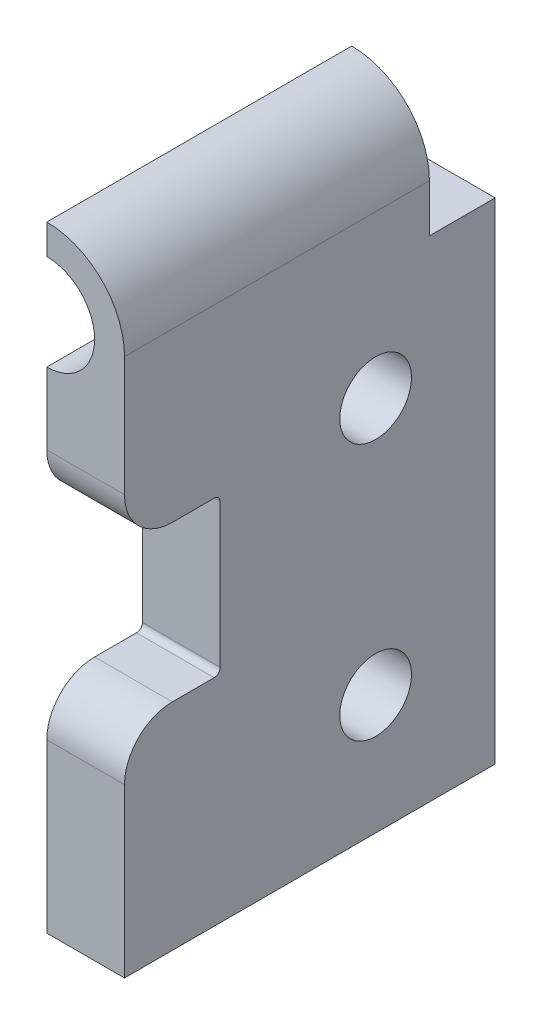
from build123d import *

# Parameters (mm, degrees)
BOSS_EXTRUDE1_DEPTH = 31
SKETCH2_W           = 5.5
SKETCH2_H           = 10.5
CUT_EXTRUDE1_DEPTH  = 7.5
SKETCH3_R           = 3
CUT_EXTRUDE2_DEPTH  = 7.5
CUT_EXTRUDE4_DEPTH  = 26.5
CUT_EXTRUDE5_REACH  = 8.5
SKETCH6_W           = 8
SKETCH6_H           = 13
FILLET1_R           = 0.5
FILLET2_R           = 4


with BuildPart() as part:
    # Sketch1 → Boss-Extrude1 (new body)
    with BuildSketch(Plane.XY):
        with BuildLine():
            Line((-3.75, 29), (-3.75, 22.5))
            Line((-3.75, 22.5), (-3.75, -22.5))
            Line((-3.75, -22.5), (2.75, -22.5))
            Line((2.75, -22.5), (2.75, 22.5))
            ThreePointArc((2.75, 22.5), (0.846194078, 27.096194078), (-3.75, 29))
        make_face()
    extrude(amount=BOSS_EXTRUDE1_DEPTH)

    # Sketch2 → Cut-Extrude1 (cut, through all)
    with BuildSketch(Plane.ZY.offset(3.75)):
        with Locations((2.75, 23.75)):
            Rectangle(SKETCH2_W, SKETCH2_H)
    extrude(amount=-CUT_EXTRUDE1_DEPTH, mode=Mode.SUBTRACT)

    # Sketch3 → Cut-Extrude2 (cut, through all)
    with BuildSketch(Plane.ZY.offset(3.75)):
        with Locations((10, 9)):
            Circle(SKETCH3_R)
        with Locations((10, -12.5)):
            Circle(SKETCH3_R)
    extrude(amount=-CUT_EXTRUDE2_DEPTH, mode=Mode.SUBTRACT)

    # Sketch4 → Cut-Extrude4 (cut, through all)
    with BuildSketch(Plane(origin=(0, 0, 5.5), x_dir=(-1, 0, 0), z_dir=(0, 0, -1))):
        with BuildLine():
            Line((3.75, 26.5), (3.75, 18.5))
            ThreePointArc((3.75, 18.5), (-0.25, 22.5), (3.75, 26.5))
        make_face()
    extrude(amount=-CUT_EXTRUDE4_DEPTH, mode=Mode.SUBTRACT)

    # Sketch6 → Cut-Extrude5 (cut, up to next)
    with BuildSketch(Plane.ZY.offset(3.75), mode=Mode.PRIVATE) as cut_extrude5_sk1:
        with Locations((27, 2)):
            Rectangle(SKETCH6_W, SKETCH6_H)
    cut_extrude5_tool1 = extrude(cut_extrude5_sk1.sketch, amount=-CUT_EXTRUDE5_REACH, mode=Mode.PRIVATE) & part.part
    add(cut_extrude5_tool1.solids().sort_by_distance((-3.75, 2, 27))[0], mode=Mode.SUBTRACT)

    # Fillet1
    fillet1_edges = [part.edges().sort_by_distance(p)[0] for p in [
        (-0.5, -4.5, 23),
        (-0.5, 8.5, 23),
    ]]
    fillet(fillet1_edges, radius=FILLET1_R)

    # Fillet2
    fillet2_edges = [part.edges().sort_by_distance(p)[0] for p in [
        (-0.5, 8.5, 31),
        (-0.5, -4.5, 31),
    ]]
    fillet(fillet2_edges, radius=FILLET2_R)


solid = part.part
